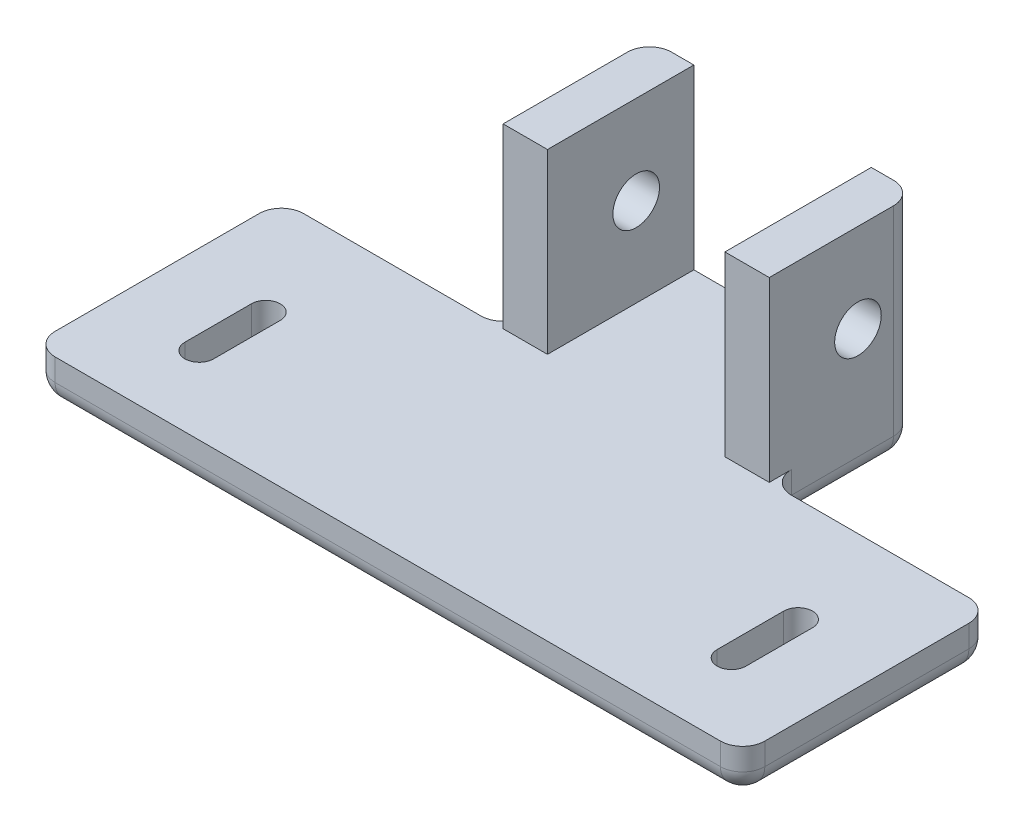
from build123d import *

# Parameters (mm, degrees)
BOSS_EXTRUDE1_START = 10
SKETCH1_W           = 16.5
SKETCH1_H           = 20
SKETCH1_R           = 2.625
BOSS_EXTRUDE1_DEPTH = 5
BOSS_EXTRUDE2_START = -10
SKETCH1_3_W         = 16.5
SKETCH1_3_H         = 20
SKETCH1_3_R         = 2.625
BOSS_EXTRUDE2_DEPTH = 5
BOSS_EXTRUDE3_START = -15
SKETCH1_4_W         = 16.5
SKETCH1_4_H         = 5
SKETCH1_4_W_2       = 28
BOSS_EXTRUDE3_DEPTH = 30
SKETCH2_W           = 25
SKETCH2_H           = 28
BOSS_EXTRUDE4_DEPTH = 5
FILLET1_R           = 2.5


with BuildPart() as part:
    # Sketch1 → Boss-Extrude1 (new body)
    with BuildSketch(Plane(origin=(0, 0, 0), x_dir=(0, 0, -1), z_dir=(1, 0, 0)).offset(BOSS_EXTRUDE1_START)):
        with Locations((-1.75, 0)):
            Rectangle(SKETCH1_W, SKETCH1_H)
        Circle(SKETCH1_R, mode=Mode.SUBTRACT)
    extrude(amount=BOSS_EXTRUDE1_DEPTH)



with BuildPart() as body_2:
    # Sketch1_3 → Boss-Extrude2 (new body)
    with BuildSketch(Plane(origin=(0, 0, 0), x_dir=(0, 0, -1), z_dir=(1, 0, 0)).offset(BOSS_EXTRUDE2_START)):
        with Locations((-1.75, 0)):
            Rectangle(SKETCH1_3_W, SKETCH1_3_H)
        Circle(SKETCH1_3_R, mode=Mode.SUBTRACT)
    extrude(amount=-BOSS_EXTRUDE2_DEPTH)


with BuildPart() as part_1:
    add(part.part)

    add(body_2.part)  # Boss-Extrude3 merges body 2
    # Sketch1_4 → Boss-Extrude3 (add)
    with BuildSketch(Plane(origin=(0, 0, 0), x_dir=(0, 0, -1), z_dir=(1, 0, 0)).offset(BOSS_EXTRUDE3_START)):
        with Locations((-1.75, -12.5)):
            Rectangle(SKETCH1_4_W, SKETCH1_4_H)
        with Locations((-24, -12.5)):
            Rectangle(SKETCH1_4_W_2, SKETCH1_4_H)
    extrude(amount=BOSS_EXTRUDE3_DEPTH)

    # Sketch2 → Boss-Extrude4 (add)
    with BuildSketch(Plane(origin=(0, -10, 0), x_dir=(1, 0, 0), z_dir=(0, 1, 0))):
        with Locations((-27.5, -24)):
            Rectangle(SKETCH2_W, SKETCH2_H)
        with BuildLine():
            Line((-31.625, -29.25), (-31.625, -21.75))
            ThreePointArc((-31.625, -21.75), (-30, -20.125), (-28.375, -21.75))
            Line((-28.375, -21.75), (-28.375, -29.25))
            ThreePointArc((-28.375, -29.25), (-30, -30.875), (-31.625, -29.25))
        make_face(mode=Mode.SUBTRACT)
        with Locations((27.5, -24)):
            Rectangle(SKETCH2_W, SKETCH2_H)
        with BuildLine():
            Line((31.625, -29.25), (31.625, -21.75))
            ThreePointArc((31.625, -21.75), (30, -20.125), (28.375, -21.75))
            Line((28.375, -21.75), (28.375, -29.25))
            ThreePointArc((28.375, -29.25), (30, -30.875), (31.625, -29.25))
        make_face(mode=Mode.SUBTRACT)
    extrude(amount=-BOSS_EXTRUDE4_DEPTH)

    # Fillet1
    fillet1_edges = [part_1.edges().sort_by_distance(p)[0] for p in [
        (0, -15, -6.5),
        (-15, -2.5, -6.5),
        (0, -15, 38),
        (-15, -15, 1.75),
        (15, -2.5, -6.5),
        (15, -15, 1.75),
        (-40, -12.5, 38),
        (-40, -12.5, 10),
        (-15, -12.5, 10),
        (-40, -15, 24),
        (-27.5, -15, 10),
        (27.5, -15, 10),
        (15, -12.5, 10),
        (40, -15, 24),
        (40, -12.5, 10),
        (40, -12.5, 38),
    ]]
    fillet(fillet1_edges, radius=FILLET1_R)


solid = part_1.part
